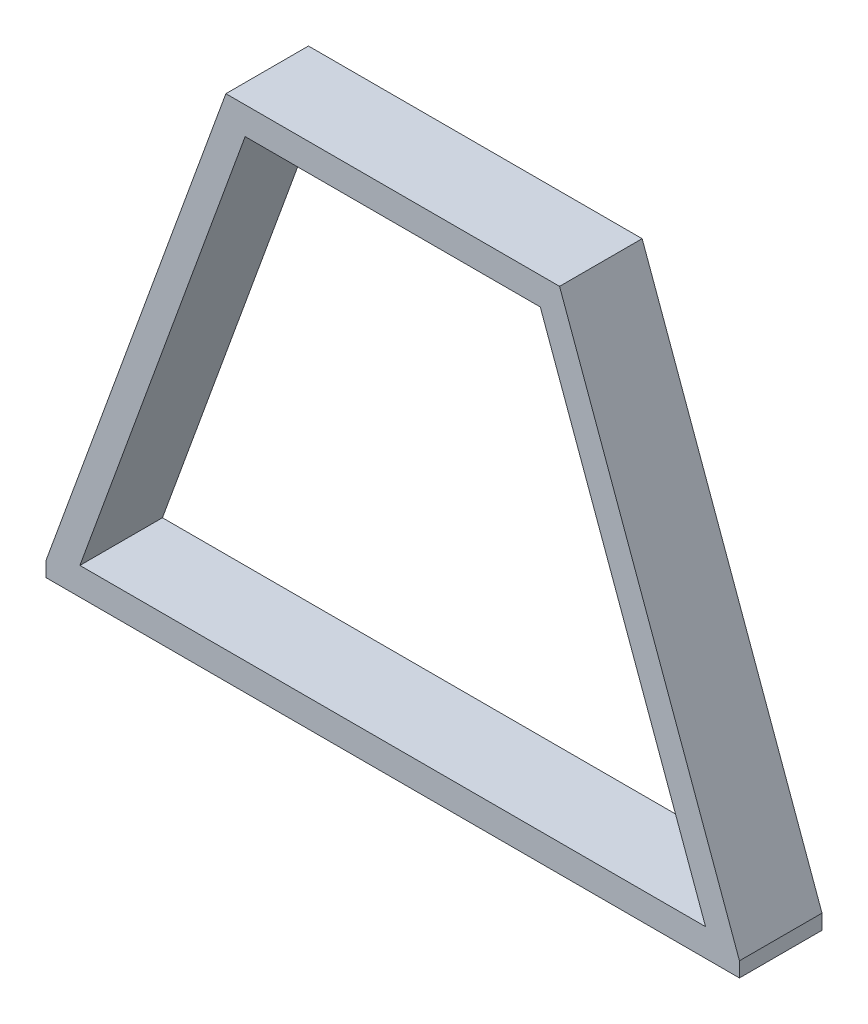
from build123d import *

# Parameters (mm, degrees)
SALIENTE_EXTRUIR1_DEPTH = 76.2
CROQUIS2_W              = 5
CROQUIS2_H              = 76.2
CORTAR_EXTRUIR1_DEPTH   = 76.2


with BuildPart() as part:
    # Croquis1 → Saliente-Extruir1 (new body)
    with BuildSketch(Plane.XY):
        Polygon((0, 0), (650, 0), (478.989928337, 469.846310393), (171.010071663, 469.846310393), align=None)
        Polygon((188.795343133, 444.446310393), (461.204656867, 444.446310393), (613.725040629, 25.4), (36.274959371, 25.4), align=None, mode=Mode.SUBTRACT)
    extrude(amount=SALIENTE_EXTRUIR1_DEPTH)

    # Croquis2 → Cortar-Extruir1 (cut)
    with BuildSketch(Plane.XZ):
        with Locations((2.5, 38.1)):
            Rectangle(CROQUIS2_W, CROQUIS2_H)
        with Locations((647.5, 38.1)):
            Rectangle(CROQUIS2_W, CROQUIS2_H)
    extrude(amount=-CORTAR_EXTRUIR1_DEPTH, mode=Mode.SUBTRACT)


solid = part.part
